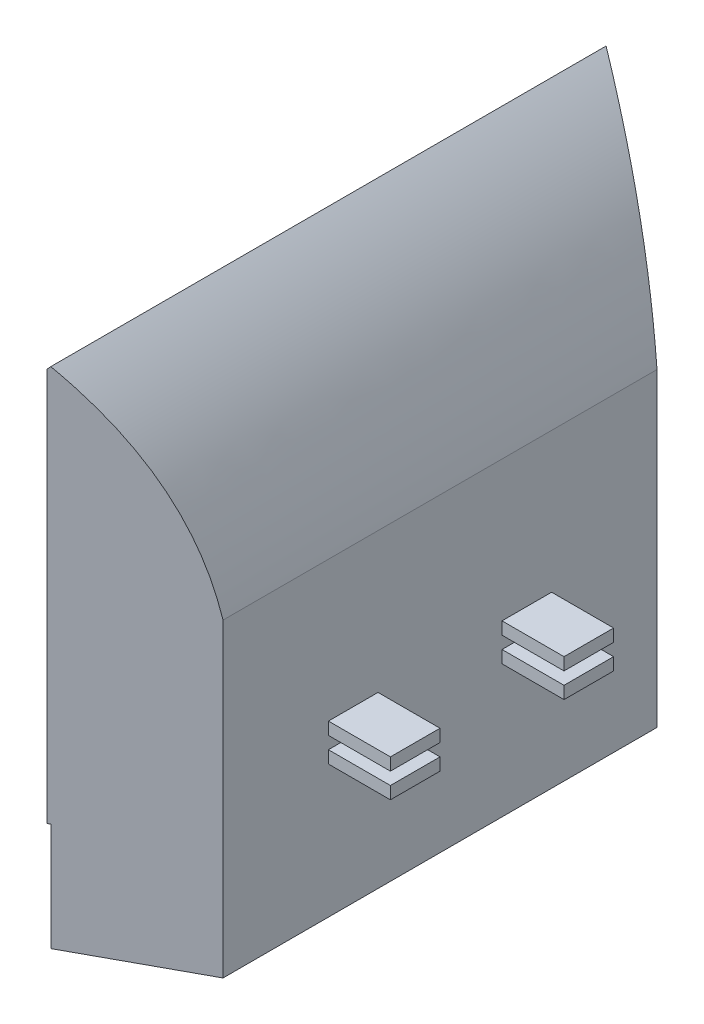
from build123d import *

# Parameters (mm, degrees)
BOSS_EXTRUDE1_DEPTH             = 450
CUT_EXTRUDE1_DEPTH              = 320.536163525
CUT_EXTRUDE1_DEPTH_BACK         = 87.9500001
BOSS_EXTRUDE2_REACH             = 321.536
BOSS_EXTRUDE2_DIRECTION_2_REACH = 88.95
SKETCH4_W                       = 40
SKETCH4_H                       = 10
BOSS_EXTRUDE3_DEPTH             = 50


with BuildPart() as part:
    # Sketch1 → Boss-Extrude1 (new body)
    with BuildSketch(Plane.XY):
        with BuildLine():
            Line((0, 0), (0, -86.95))
            Line((0, -86.95), (90, -86.95))
            Line((90, -86.95), (90, 163.05))
            add(Edge.make_bspline(
                [(90, 163.05), (72.317416943, 256.499426115), (1.7e-06, 319.536163425)],
                knots=[0, 0, 0, 1, 1, 1], degree=2))
            Line((1.7e-06, 319.536163425), (-1.971240178, 317.274702513))
            add(Edge.make_bspline(
                [(87, 162.76796294), (86.63530579, 164.685544789), (85.866737034, 168.522541651), (84.193801862, 176.09415534), (81.838470508, 185.417428941), (78.592614297, 196.364076295), (73.704594381, 210.644362496), (66.544776494, 227.902696365), (56.272326819, 247.671791898), (44.316806262, 266.505130738), (32.948415938, 281.423453125), (23.007866651, 292.89431167), (15.129804099, 301.265055213), (8.209142943, 308.04969842), (2.465529724, 313.357146881), (-0.486511784, 315.980513091), (-1.971240178, 317.274702513)],
                knots=[0.001490309, 0.001490309, 0.001490309, 0.001490309, 0.032693737, 0.063897165, 0.12630402, 0.188710876, 0.251117732, 0.375931443, 0.500745154, 0.625558866, 0.750372577, 0.812779433, 0.875186289, 0.937593144, 0.968796572, 1, 1, 1, 1], degree=3))
            Line((87, 162.76796294), (87, -83.95))
            Line((87, -83.95), (3, -83.95))
            Line((3, -83.95), (3, 0))
            Line((3, 0), (0, 0))
        make_face()
    extrude(amount=BOSS_EXTRUDE1_DEPTH)

    # Sketch2 → Cut-Extrude1 (cut, two sides)
    with BuildSketch(Plane(origin=(0, 0, 0), x_dir=(1, 0, 0), z_dir=(0, 1, 0))) as cut_extrude1_sk:
        Polygon((-1.971240178, -450), (90, -400), (90, -450), align=None)
        Polygon((90, 0), (90, -50), (-1.971240178, 0), align=None)
    extrude(amount=CUT_EXTRUDE1_DEPTH, mode=Mode.SUBTRACT)
    extrude(cut_extrude1_sk.sketch, amount=-CUT_EXTRUDE1_DEPTH_BACK, mode=Mode.SUBTRACT)

    # Sketch3 → Boss-Extrude2 (add, up to next)
    with BuildSketch(Plane(origin=(0, 0, 0), x_dir=(1, 0, 0), z_dir=(0, 1, 0)), mode=Mode.PRIVATE) as boss_extrude2_sk1:
        Polygon((-1.971240178, -446), (90, -396), (90, -400), (-1.971240178, -450), align=None)
    boss_extrude2_tool1 = extrude(boss_extrude2_sk1.sketch, amount=BOSS_EXTRUDE2_REACH, mode=Mode.PRIVATE) - part.part
    add(boss_extrude2_tool1.solids().sort_by_distance((44.01438, 0, 423))[0])
    # Sketch3 → Boss-Extrude2 (add, up to next)
    with BuildSketch(Plane(origin=(0, 0, 0), x_dir=(1, 0, 0), z_dir=(0, 1, 0)), mode=Mode.PRIVATE) as boss_extrude2_sk2:
        Polygon((-1.971240178, -4), (-1.971240178, 0), (90, -50), (90, -54), align=None)
    boss_extrude2_tool2 = extrude(boss_extrude2_sk2.sketch, amount=BOSS_EXTRUDE2_REACH, mode=Mode.PRIVATE) - part.part
    add(boss_extrude2_tool2.solids().sort_by_distance((44.01438, 0, 27))[0])

    # Sketch3 → Boss-Extrude2 direction 2 (add, up to next)
    with BuildSketch(Plane(origin=(0, 0, 0), x_dir=(1, 0, 0), z_dir=(0, 1, 0)), mode=Mode.PRIVATE) as boss_extrude2_direction_2_sk1:
        Polygon((-1.971240178, -446), (90, -396), (90, -400), (-1.971240178, -450), align=None)
    boss_extrude2_direction_2_tool1 = extrude(boss_extrude2_direction_2_sk1.sketch, amount=-BOSS_EXTRUDE2_DIRECTION_2_REACH, mode=Mode.PRIVATE) - part.part
    add(boss_extrude2_direction_2_tool1.solids().sort_by_distance((44.01438, 0, 423))[0])
    # Sketch3 → Boss-Extrude2 direction 2 (add, up to next)
    with BuildSketch(Plane(origin=(0, 0, 0), x_dir=(1, 0, 0), z_dir=(0, 1, 0)), mode=Mode.PRIVATE) as boss_extrude2_direction_2_sk2:
        Polygon((-1.971240178, -4), (-1.971240178, 0), (90, -50), (90, -54), align=None)
    boss_extrude2_direction_2_tool2 = extrude(boss_extrude2_direction_2_sk2.sketch, amount=-BOSS_EXTRUDE2_DIRECTION_2_REACH, mode=Mode.PRIVATE) - part.part
    add(boss_extrude2_direction_2_tool2.solids().sort_by_distance((44.01438, 0, 27))[0])

    # Sketch4 → Boss-Extrude3 (add)
    with BuildSketch(Plane(origin=(90, 0, 0), x_dir=(0, 0, -1), z_dir=(1, 0, 0))):
        with Locations((-295, 25)):
            Rectangle(SKETCH4_W, SKETCH4_H)
        with Locations((-155, 45)):
            Rectangle(SKETCH4_W, SKETCH4_H)
        with Locations((-155, 25)):
            Rectangle(SKETCH4_W, SKETCH4_H)
        with Locations((-295, 45)):
            Rectangle(SKETCH4_W, SKETCH4_H)
    extrude(amount=BOSS_EXTRUDE3_DEPTH)


solid = part.part
